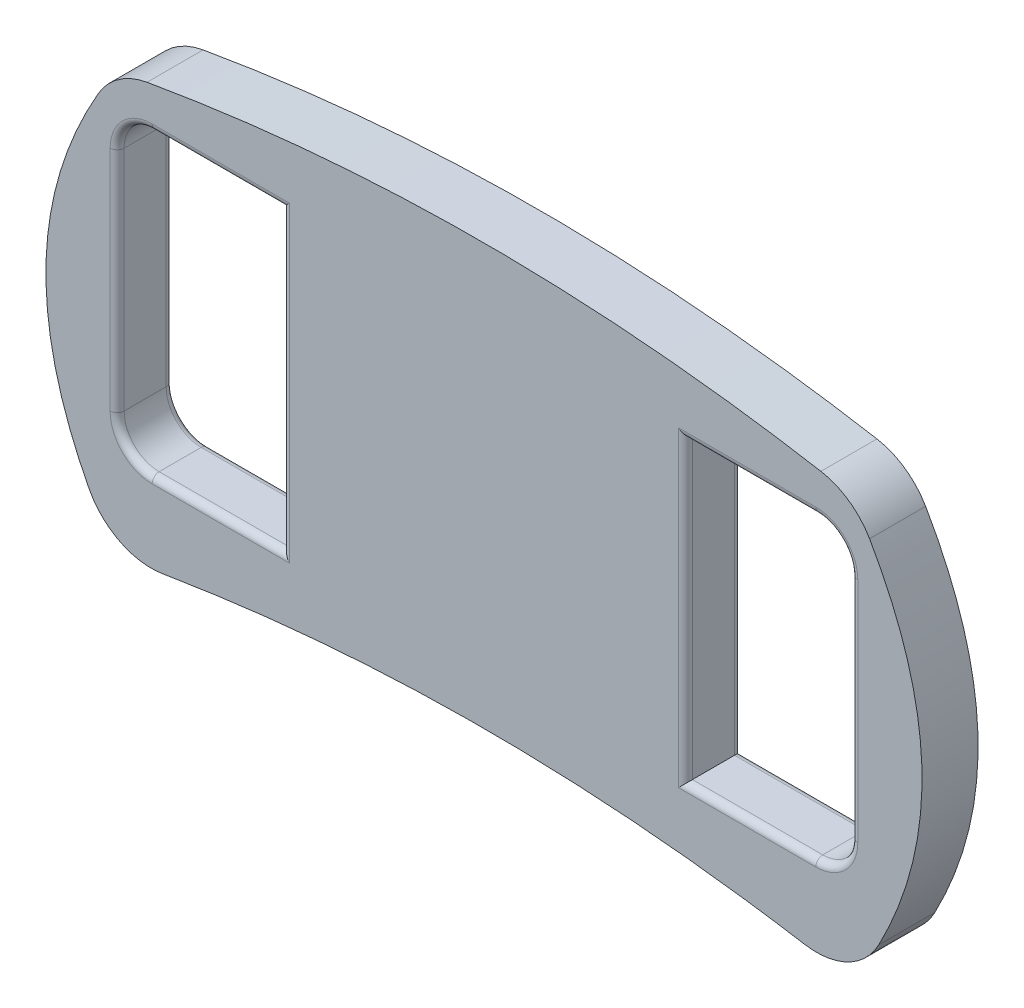
from build123d import *

# Parameters (mm, degrees)
BOSS_EXTRUDE2_DEPTH = 20.32
FILLET1_R           = 25.4
FILLET2_R           = 25.4
FILLET3_R           = 25.4
FILLET4_R           = 25.4
CUT_EXTRUDE1_DEPTH  = 20.32
FILLET5_R           = 2.54


with BuildPart() as part:
    # Sketch1 → Boss-Extrude2 (new body)
    with BuildSketch(Plane.XY):
        with BuildLine():
            add(Edge.make_bspline(
                [(-131.195332136, 32.798833034), (2.154667864, 58.198833034), (135.504667864, 32.798833034)],
                knots=[0, 0, 0, 1, 1, 1], degree=2))
            add(Edge.make_bspline(
                [(135.504667864, 32.798833034), (186.304667864, -43.401166966), (135.504667864, -119.601166966)],
                knots=[0, 0, 0, 1, 1, 1], degree=2))
            add(Edge.make_bspline(
                [(-131.195332136, -119.601166966), (2.154667864, -94.201166966), (135.504667864, -119.601166966)],
                knots=[0, 0, 0, 1, 1, 1], degree=2))
            add(Edge.make_bspline(
                [(-131.195332136, 32.798833034), (-181.995332136, -43.401166966), (-131.195332136, -119.601166966)],
                knots=[0, 0, 0, 1, 1, 1], degree=2))
        make_face()
    extrude(amount=BOSS_EXTRUDE2_DEPTH)

    # Fillet1
    fillet1_edges = [part.edges().sort_by_distance(p)[0] for p in [
        (135.504667864, -119.601166966, 10.16),
    ]]
    fillet(fillet1_edges, radius=FILLET1_R)

    # Fillet2
    fillet2_edges = [part.edges().sort_by_distance(p)[0] for p in [
        (-131.195332136, -119.601166966, 10.16),
    ]]
    fillet(fillet2_edges, radius=FILLET2_R)

    # Fillet3
    fillet3_edges = [part.edges().sort_by_distance(p)[0] for p in [
        (135.504667864, 32.798833034, 10.16),
    ]]
    fillet(fillet3_edges, radius=FILLET3_R)

    # Fillet4
    fillet4_edges = [part.edges().sort_by_distance(p)[0] for p in [
        (-131.195332136, 32.798833034, 10.16),
    ]]
    fillet(fillet4_edges, radius=FILLET4_R)

    # Sketch2 → Cut-Extrude1 (cut)
    with BuildSketch(Plane.XY.offset(20.32)):
        with BuildLine():
            Line((-118.089671205, 20.173896233), (-70.845671205, 20.173896233))
            Line((-70.845671205, 20.173896233), (-70.845671205, -87.716522063))
            Line((-70.845671205, -87.716522063), (-118.089671205, -87.716522063))
            ThreePointArc((-118.089671205, -87.716522063), (-127.069927326, -83.996778184), (-130.789671205, -75.016522063))
            Line((-130.789671205, -75.016522063), (-130.789671205, 7.473896233))
            ThreePointArc((-130.789671205, 7.473896233), (-127.069927326, 16.454152354), (-118.089671205, 20.173896233))
        make_face()
        with BuildLine():
            Line((135.099006932, 7.473896233), (135.099006932, -75.016522063))
            ThreePointArc((135.099006932, -75.016522063), (131.379263053, -83.996778184), (122.399006932, -87.716522063))
            Line((122.399006932, -87.716522063), (75.155006932, -87.716522063))
            Line((75.155006932, -87.716522063), (75.155006932, 20.173896233))
            Line((75.155006932, 20.173896233), (122.399006932, 20.173896233))
            ThreePointArc((122.399006932, 20.173896233), (131.379263053, 16.454152354), (135.099006932, 7.473896233))
        make_face()
    extrude(amount=-CUT_EXTRUDE1_DEPTH, mode=Mode.SUBTRACT)

    # Fillet5
    fillet5_edges = [part.edges().sort_by_distance(p)[0] for p in [
        (-127.069927326, 16.454152354, 0),
        (-94.467671205, 20.173896233, 20.32),
        (-70.845671205, -33.771312915, 20.32),
        (-94.467671205, -87.716522063, 0),
        (-127.069927326, -83.996778184, 0),
        (-130.789671205, -33.771312915, 0),
        (-94.467671205, 20.173896233, 0),
        (-70.845671205, -33.771312915, 0),
        (-127.069927326, 16.454152354, 20.32),
        (-130.789671205, -33.771312915, 20.32),
        (-127.069927326, -83.996778184, 20.32),
        (-94.467671205, -87.716522063, 20.32),
        (98.777006932, 20.173896233, 20.32),
        (131.379263053, 16.454152354, 20.32),
        (135.099006932, -33.771312915, 20.32),
        (131.379263053, -83.996778184, 0),
        (98.777006932, -87.716522063, 0),
        (75.155006932, -33.771312915, 0),
        (98.777006932, 20.173896233, 0),
        (131.379263053, 16.454152354, 0),
        (135.099006932, -33.771312915, 0),
        (75.155006932, -33.771312915, 20.32),
        (98.777006932, -87.716522063, 20.32),
        (131.379263053, -83.996778184, 20.32),
    ]]
    fillet(fillet5_edges, radius=FILLET5_R)


solid = part.part
